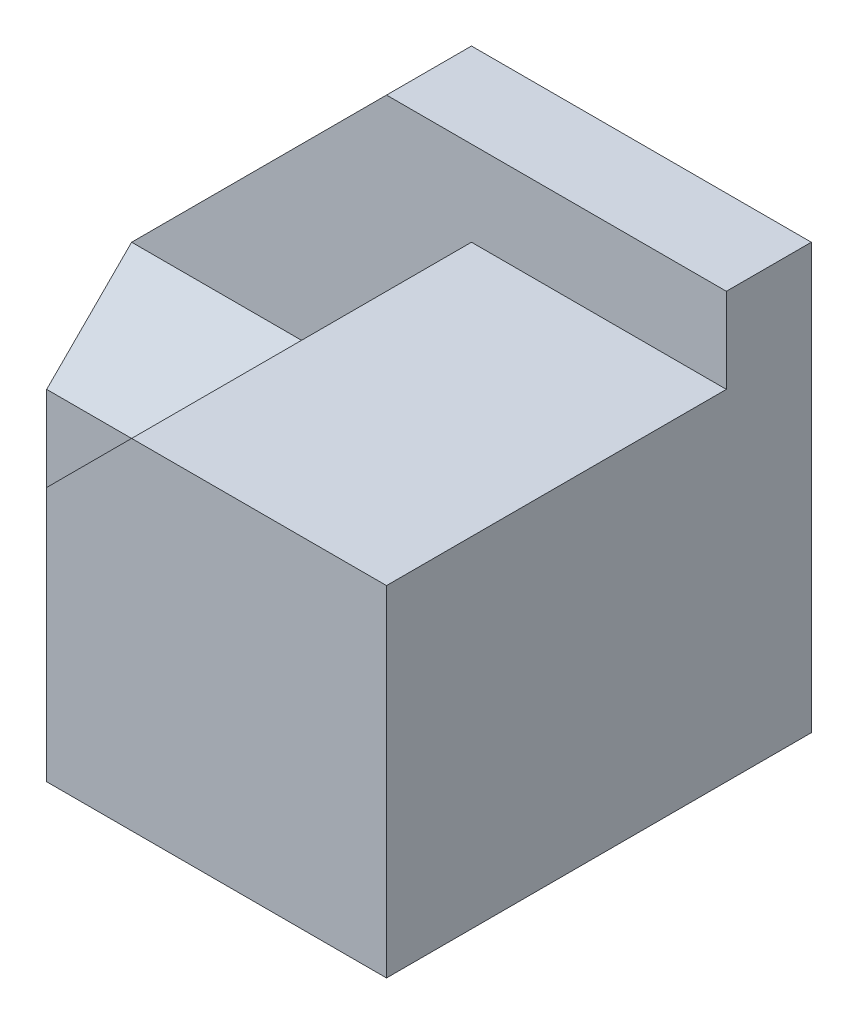
from build123d import *

# Parameters (mm, degrees)
SKETCH1_W           = 70
SKETCH1_H           = 50
BOSS_EXTRUDE1_DEPTH = 50
CUT_EXTRUDE1_DEPTH  = 50
SKETCH3_W           = 40
SKETCH3_H           = 10
CUT_EXTRUDE2_DEPTH  = 50
CUT_EXTRUDE3_DEPTH  = 20
CUT_EXTRUDE4_DEPTH  = 10
CUT_EXTRUDE6_DEPTH  = 30
CUT_EXTRUDE7_DEPTH  = 30
CUT_EXTRUDE9_DEPTH  = 10
BOSS_EXTRUDE2_DEPTH = 43
CUT_EXTRUDE10_DEPTH = 10


with BuildPart() as part:
    # Sketch1 → Boss-Extrude1 (new body)
    with BuildSketch(Plane.XY):
        with Locations((35, 25)):
            Rectangle(SKETCH1_W, SKETCH1_H)
    extrude(amount=BOSS_EXTRUDE1_DEPTH)

    # Sketch2 → Cut-Extrude1 (cut)
    with BuildSketch(Plane.XY.offset(50)):
        Polygon((0, 20), (30, 50), (0, 50), align=None)
    extrude(amount=-CUT_EXTRUDE1_DEPTH, mode=Mode.SUBTRACT)

    # Sketch3 → Cut-Extrude2 (cut)
    with BuildSketch(Plane(origin=(70, 0, 0), x_dir=(0, 0, -1), z_dir=(1, 0, 0))):
        with Locations((-30, 45)):
            Rectangle(SKETCH3_W, SKETCH3_H)
    extrude(amount=-CUT_EXTRUDE2_DEPTH, mode=Mode.SUBTRACT)

    # Sketch4 → Cut-Extrude3 (cut)
    with BuildSketch(Plane.XY.offset(50)):
        Polygon((30, 30), (40, 40), (20, 40), (0, 20), (0, 0), (30, 0), align=None)
    extrude(amount=-CUT_EXTRUDE3_DEPTH, mode=Mode.SUBTRACT)

    # Sketch5 → Cut-Extrude4 (cut)
    with BuildSketch(Plane.XY.offset(30)):
        Polygon((0, 10), (10, 10), (40, 40), (20, 40), (0, 20), align=None)
    extrude(amount=-CUT_EXTRUDE4_DEPTH, mode=Mode.SUBTRACT)

    # Sketch6 → Cut-Extrude6 (cut)
    with BuildSketch(Plane.ZY):
        Polygon((30, 10), (20, 0), (30, 0), align=None)
    extrude(amount=-CUT_EXTRUDE6_DEPTH, mode=Mode.SUBTRACT)

    # Sketch7 → Cut-Extrude7 (cut)
    with BuildSketch(Plane.ZY):
        Polygon((30, 10), (20, 10), (20, 0), align=None)
    extrude(amount=-CUT_EXTRUDE7_DEPTH, mode=Mode.SUBTRACT)

    # Sketch9 → Cut-Extrude9 (cut)
    with BuildSketch(Plane.XY.offset(20)):
        Polygon((20, 40), (40, 40), (10, 10), (0, 10), (0, 20), align=None)
    extrude(amount=-CUT_EXTRUDE9_DEPTH, mode=Mode.SUBTRACT)

    # Sketch10 → Boss-Extrude2 (add)
    with BuildSketch(Plane.ZY):
        Polygon((10, 20), (20, 10), (10, 10), align=None)
    extrude(amount=-BOSS_EXTRUDE2_DEPTH)

    # Sketch13 → Cut-Extrude10 (cut)
    with BuildSketch(Plane.XY.offset(30)):
        Polygon((10, 10), (30, 10), (30, 30), align=None)
    extrude(amount=-CUT_EXTRUDE10_DEPTH, mode=Mode.SUBTRACT)


solid = part.part
